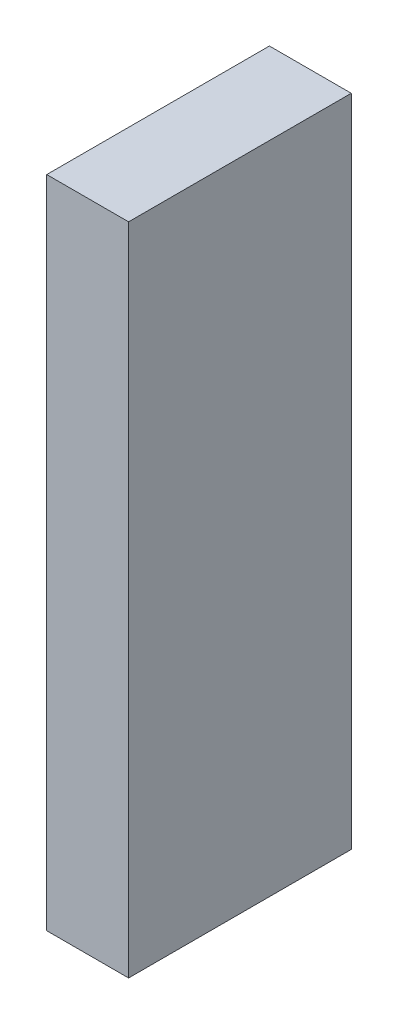
from build123d import *

# Parameters (mm, degrees)
SKETCH1_W           = 8.636
SKETCH1_H           = 25.4
BOSS_EXTRUDE1_DEPTH = 3.175


with BuildPart() as part:
    # Sketch1 → Boss-Extrude1 (new body)
    with BuildSketch(Plane(origin=(0, 0, 0), x_dir=(0, 0, -1), z_dir=(1, 0, 0))):
        Rectangle(SKETCH1_W, SKETCH1_H)
    extrude(amount=BOSS_EXTRUDE1_DEPTH)


solid = part.part
